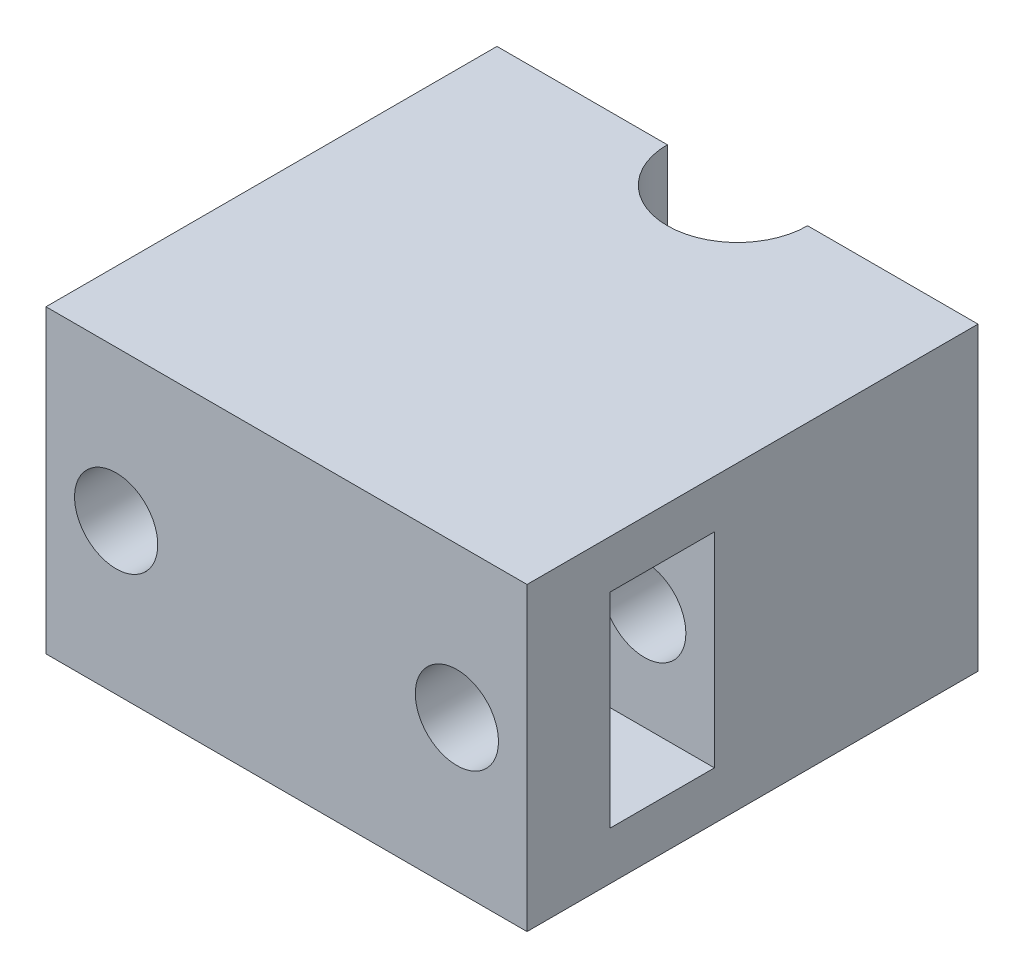
from build123d import *

# Parameters (mm, degrees)
SKETCH1_W               = 48
SKETCH1_H               = 45
BOSS_EXTRUDE1_DEPTH     = 30
SKETCH2_W               = 10.4
SKETCH2_H               = 20.4
CUT_EXTRUDE1_DEPTH      = 45
SKETCH3_R               = 4.15
CUT_EXTRUDE2_DEPTH      = 46
CUT_EXTRUDE3_DEPTH      = 1
CUT_EXTRUDE3_DEPTH_BACK = 31


with BuildPart() as part:
    # Sketch1 → Boss-Extrude1 (new body)
    with BuildSketch(Plane(origin=(0, 0, 0), x_dir=(1, 0, 0), z_dir=(0, 1, 0))):
        Rectangle(SKETCH1_W, SKETCH1_H)
    extrude(amount=BOSS_EXTRUDE1_DEPTH)

    # Sketch2 → Cut-Extrude1 (cut)
    with BuildSketch(Plane(origin=(24, 0, 0), x_dir=(0, 0, -1), z_dir=(1, 0, 0))):
        with Locations((-9, 15)):
            Rectangle(SKETCH2_W, SKETCH2_H)
    extrude(amount=-CUT_EXTRUDE1_DEPTH, mode=Mode.SUBTRACT)

    # Sketch3 → Cut-Extrude2 (cut, through all)
    with BuildSketch(Plane.XY.offset(22.5)):
        with Locations((-17, 15)):
            Circle(SKETCH3_R)
        with Locations((17, 15)):
            Circle(SKETCH3_R)
    extrude(amount=-CUT_EXTRUDE2_DEPTH, mode=Mode.SUBTRACT)

    # Sketch4 → Cut-Extrude3 (cut, two sides)
    with BuildSketch(Plane(origin=(0, 30, 0), x_dir=(1, 0, 0), z_dir=(0, 1, 0))) as cut_extrude3_sk:
        with BuildLine():
            Line((-7, 141.788608739), (-7, 22.5))
            ThreePointArc((-7, 22.5), (0, 15.5), (7, 22.5))
            Line((7, 22.5), (7, 141.788608739))
            Line((7, 141.788608739), (7, 380.365826216))
            Line((7, 380.365826216), (-7, 380.365826216))
            Line((-7, 380.365826216), (-7, 141.788608739))
        make_face()
    extrude(amount=CUT_EXTRUDE3_DEPTH, mode=Mode.SUBTRACT)
    extrude(cut_extrude3_sk.sketch, amount=-CUT_EXTRUDE3_DEPTH_BACK, mode=Mode.SUBTRACT)


solid = part.part
